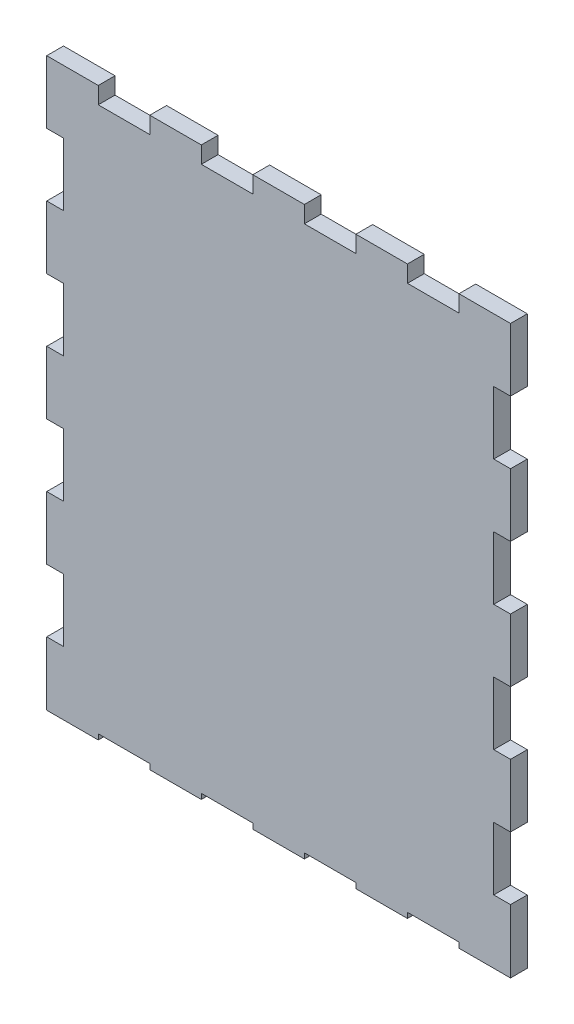
from build123d import *

# Parameters (mm, degrees)
SKETCH2_W           = 137.16
SKETCH2_H           = 167.64
BOSS_EXTRUDE1_DEPTH = 4.9609375
SKETCH3_W           = 4.9609502
SKETCH3_H           = 18.5928
SKETCH3_W_2         = 15.24
SKETCH3_H_2         = 4.9609502
SKETCH3_H_3         = 1.5875
CUT_EXTRUDE1_DEPTH  = 5.9609375


with BuildPart() as part:
    # Sketch2 → Boss-Extrude1 (new body)
    with BuildSketch(Plane.XY):
        Rectangle(SKETCH2_W, SKETCH2_H)
    extrude(amount=BOSS_EXTRUDE1_DEPTH)

    # Sketch3 → Cut-Extrude1 (cut, through all)
    with BuildSketch(Plane.XY.offset(4.9609375)):
        with Locations((-66.0995249, 18.6944)):
            Rectangle(SKETCH3_W, SKETCH3_H)
        with Locations((-66.0995249, 55.9054)):
            Rectangle(SKETCH3_W, SKETCH3_H)
        with Locations((-66.0995249, -18.5166)):
            Rectangle(SKETCH3_W, SKETCH3_H)
        with Locations((-66.0995249, -55.7276)):
            Rectangle(SKETCH3_W, SKETCH3_H)
        with Locations((66.0995249, 18.6944)):
            Rectangle(SKETCH3_W, SKETCH3_H)
        with Locations((66.0995249, 55.9054)):
            Rectangle(SKETCH3_W, SKETCH3_H)
        with Locations((66.0995249, -18.5166)):
            Rectangle(SKETCH3_W, SKETCH3_H)
        with Locations((66.0995249, -55.7276)):
            Rectangle(SKETCH3_W, SKETCH3_H)
        with Locations((-15.24, 81.3395249)):
            Rectangle(SKETCH3_W_2, SKETCH3_H_2)
        with Locations((-45.72, 81.3395249)):
            Rectangle(SKETCH3_W_2, SKETCH3_H_2)
        with Locations((15.24, 81.3395249)):
            Rectangle(SKETCH3_W_2, SKETCH3_H_2)
        with Locations((45.72, 81.3395249)):
            Rectangle(SKETCH3_W_2, SKETCH3_H_2)
        with Locations((-15.24, -83.02625)):
            Rectangle(SKETCH3_W_2, SKETCH3_H_3)
        with Locations((-45.72, -83.02625)):
            Rectangle(SKETCH3_W_2, SKETCH3_H_3)
        with Locations((15.24, -83.02625)):
            Rectangle(SKETCH3_W_2, SKETCH3_H_3)
        with Locations((45.72, -83.02625)):
            Rectangle(SKETCH3_W_2, SKETCH3_H_3)
    extrude(amount=-CUT_EXTRUDE1_DEPTH, mode=Mode.SUBTRACT)


solid = part.part
